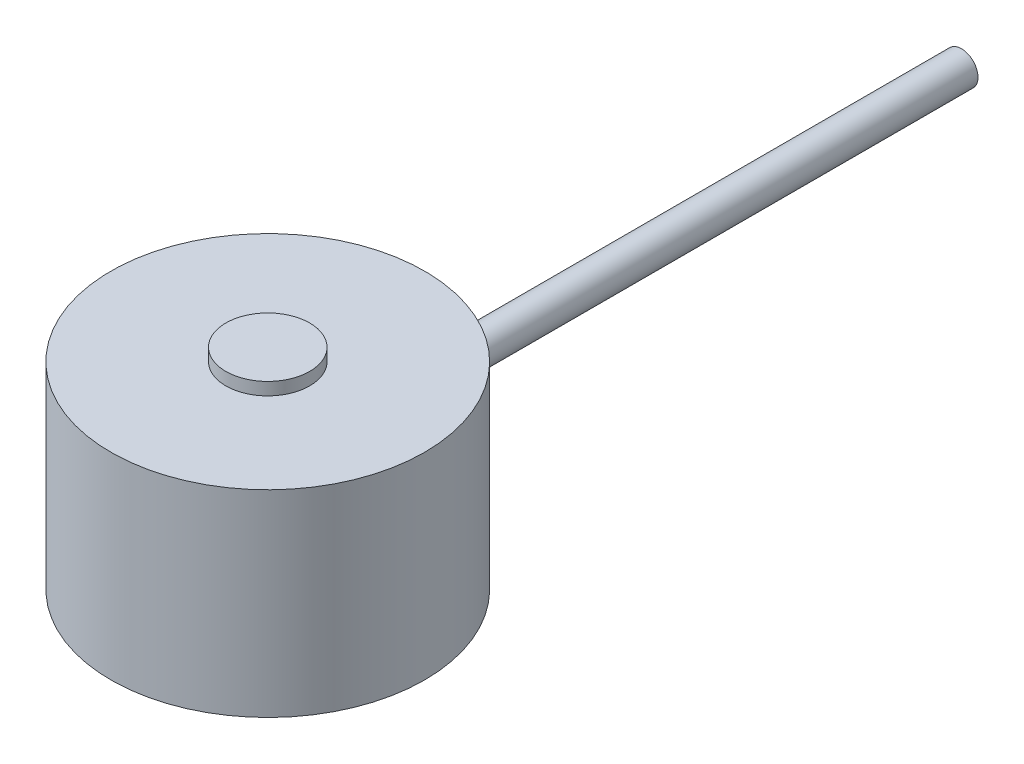
from build123d import *

# Parameters (mm, degrees)
SKETCH3_R           = 1
BOSS_EXTRUDE1_DEPTH = 42


with BuildPart() as part:
    # Sketch2 → Revolve1 (revolve)
    with BuildSketch(Plane.XY):
        Polygon((0, 0), (0, 12.7), (2.54, 12.7), (2.54, 11.94), (9.5, 11.94), (9.5, 0), align=None)
    revolve(axis=Axis((0, 0, 0), (0, 1, 0)))

    # Sketch3 → Boss-Extrude1 (add)
    with BuildSketch(Plane.XY):
        with Locations((0, 6.35)):
            Circle(SKETCH3_R)
    extrude(amount=-BOSS_EXTRUDE1_DEPTH)


solid = part.part
